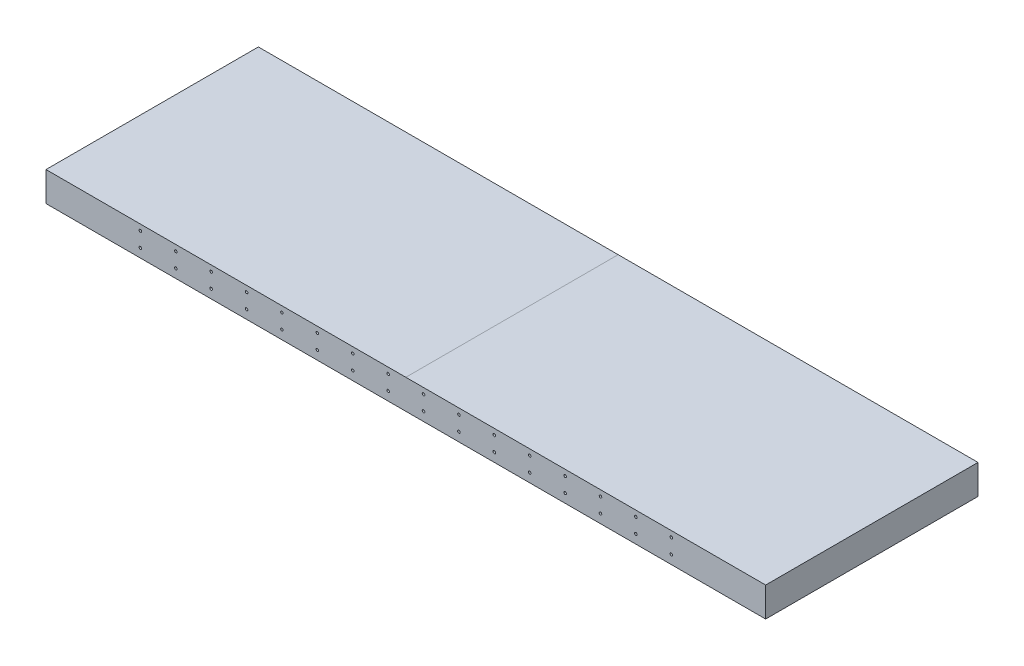
from build123d import *

# Parameters (mm, degrees)
SKETCH1_W           = 1549.4
SKETCH1_H           = 63.5
BOSS_EXTRUDE1_DEPTH = 457.2
HOLE1_D             = 5.588
HOLE1_DEPTH         = 5.08
LPATTERN1_COUNT     = 4
LPATTERN1_PITCH     = 25.4
HOLE2_D             = 5.588
HOLE2_DEPTH         = 5.08
LPATTERN2_COUNT     = 4
LPATTERN2_PITCH     = 25.4
HOLE3_D             = 5.588
HOLE3_DEPTH         = 5.08
LPATTERN3_COUNT     = 16
LPATTERN3_PITCH     = 76.2


with BuildPart() as part:
    # Sketch1 → Boss-Extrude1 (new body)
    with BuildSketch(Plane.XY):
        with Locations((774.7, 31.75)):
            Rectangle(SKETCH1_W, SKETCH1_H)
    extrude(amount=-BOSS_EXTRUDE1_DEPTH)

    # Hole1
    with Locations(Plane(origin=(38.1, 55.5625, -457.2), x_dir=(-1, 0, 0), z_dir=(0, 0, -1))):
        with Locations((0, 0), (0, -47.625)):
            hole1 = Hole(HOLE1_D / 2, depth=HOLE1_DEPTH)

    # LPattern1: Hole1 ×4
    with Locations(*[(i * LPATTERN1_PITCH, 0, 0) for i in range(1, LPATTERN1_COUNT)]):
        add(hole1, mode=Mode.SUBTRACT)

    # Hole2
    with Locations(Plane(origin=(1511.3, 55.5625, -457.2), x_dir=(-1, 0, 0), z_dir=(0, 0, -1))):
        with Locations((0, 0), (0, -47.625)):
            hole2 = Hole(HOLE2_D / 2, depth=HOLE2_DEPTH)

    # LPattern2: Hole2 ×4
    with Locations(*[(-i * LPATTERN2_PITCH, 0, 0) for i in range(1, LPATTERN2_COUNT)]):
        add(hole2, mode=Mode.SUBTRACT)

    # Hole3
    with Locations(Plane(origin=(203.2, 50.8, 0), x_dir=(1, 0, 0), z_dir=(0, 0, 1))):
        with Locations((0, 0), (0, -31.75)):
            hole3 = Hole(HOLE3_D / 2, depth=HOLE3_DEPTH)

    # LPattern3: Hole3 ×16
    with Locations(*[(i * LPATTERN3_PITCH, 0, 0) for i in range(1, LPATTERN3_COUNT)]):
        add(hole3, mode=Mode.SUBTRACT)


solid = part.part
